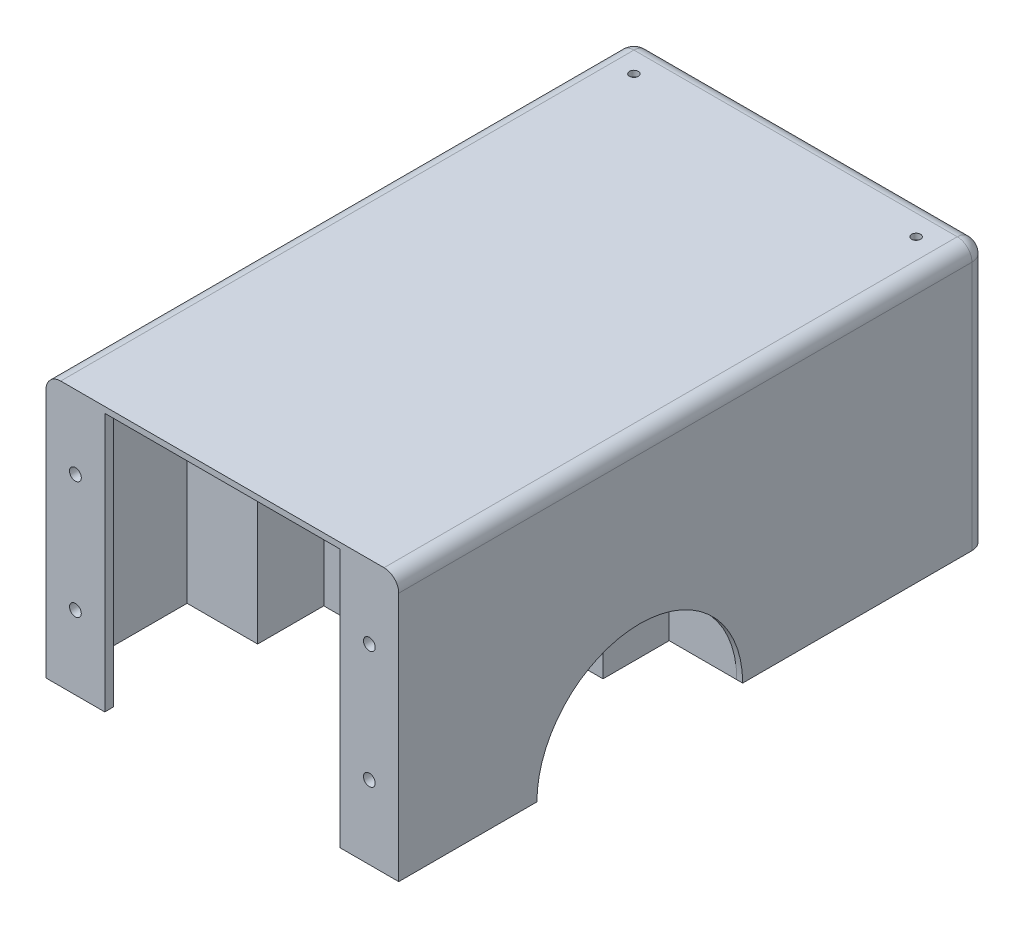
from build123d import *

# Parameters (mm, degrees)
BOSS_EXTRUDE1_DEPTH = 60
FILLET1_R           = 5
SHELL1_T            = -2
SKETCH2_R           = 2.675
BOSS_EXTRUDE2_DEPTH = 27
SKETCH3_R           = 1.425
CUT_EXTRUDE1_DEPTH  = 4
SKETCH4_W           = 18
SKETCH4_H           = 3
BOSS_EXTRUDE3_DEPTH = 88
SKETCH5_R           = 2
CUT_EXTRUDE2_DEPTH  = 3
BOSS_EXTRUDE4_DEPTH = 88
SKETCH8_R           = 1.5
CUT_EXTRUDE3_DEPTH  = 2
SKETCH9_R           = 2.5
BOSS_EXTRUDE5_DEPTH = 1
SKETCH10_R          = 4
SKETCH10_R_2        = 1.5
SKETCH10_R_3        = 2
CUT_EXTRUDE4_DEPTH  = 1
SKETCH11_R          = 2.425
SKETCH11_R_2        = 1.425
BOSS_EXTRUDE6_DEPTH = 3


with BuildPart() as part:
    # Sketch1 → Boss-Extrude1 (new body)
    with BuildSketch(Plane(origin=(0, 0, 0), x_dir=(0, 0, -1), z_dir=(1, 0, 0))):
        with BuildLine():
            Line((35, 0), (118, 0))
            Line((118, 0), (118, 90))
            Line((118, 90), (-82, 90))
            Line((-82, 90), (-82, 0))
            Line((-82, 0), (-35, 0))
            ThreePointArc((-35, 0), (0, 35), (35, 0))
        make_face()
    extrude(amount=BOSS_EXTRUDE1_DEPTH)

    # Fillet1
    fillet1_edges = [part.edges().sort_by_distance(p)[0] for p in [
        (60, 45, -118),
        (30, 90, -118),
        (60, 90, -18),
    ]]
    fillet(fillet1_edges, radius=FILLET1_R)

    # Shell1
    shell1_openings = [part.faces().sort_by_distance(p)[0] for p in [
        (30, 0, 58.5),
        (29.971275261, 44.956357534, 82),
        (29.96885008, 0, -76.456447556),
        (30, 17.5, 0),
        (0, 48.594891541, -20.122257458),
    ]]
    offset(amount=SHELL1_T, openings=shell1_openings, kind=Kind.INTERSECTION)

    # Sketch2 → Boss-Extrude2 (add)
    with BuildSketch(Plane.XZ.offset(-88)):
        with Locations(Location((41, -76, 0), (0, 0, 270))):  # turned: the seam where the file's is
            Circle(SKETCH2_R)
    extrude(amount=BOSS_EXTRUDE2_DEPTH)

    # Sketch3 → Cut-Extrude1 (cut)
    with BuildSketch(Plane.XZ.offset(-61)):
        with Locations(Location((41, -76, 0), (0, 0, 270))):  # turned: the seam where the file's is
            Circle(SKETCH3_R)
    extrude(amount=-CUT_EXTRUDE1_DEPTH, mode=Mode.SUBTRACT)

    # Sketch4 → Boss-Extrude3 (add)
    with BuildSketch(Plane.XZ):
        with Locations((49, 80.5)):
            Rectangle(SKETCH4_W, SKETCH4_H)
    extrude(amount=-BOSS_EXTRUDE3_DEPTH)

    # Sketch5 → Cut-Extrude2 (cut)
    with BuildSketch(Plane.XY.offset(82)):
        with Locations((50, 25)):
            Circle(SKETCH5_R)
        with Locations((50, 65)):
            Circle(SKETCH5_R)
    extrude(amount=-CUT_EXTRUDE2_DEPTH, mode=Mode.SUBTRACT)

    # Sketch6 → Boss-Extrude4 (add)
    with BuildSketch(Plane.XZ):
        Polygon((58, 35), (35, 35), (35, 12.5), (15, 12.5), (15, -12.5), (35, -12.5), (35, -35), (58, -35), (58, -36), (34, -36), (34, -13.5), (14, -13.5), (14, 13.5), (34, 13.5), (34, 36), (58, 36), align=None)
    extrude(amount=-BOSS_EXTRUDE4_DEPTH)

    # Sketch8 → Cut-Extrude3 (cut)
    with BuildSketch(Plane(origin=(0, 90, 0), x_dir=(1, 0, 0), z_dir=(0, 1, 0))):
        with Locations(Location((48, 106, 0), (0, 0, 270))):  # turned: the seam where the file's is
            Circle(SKETCH8_R)
    extrude(amount=-CUT_EXTRUDE3_DEPTH, mode=Mode.SUBTRACT)

    # Sketch9 → Boss-Extrude5 (add)
    with BuildSketch(Plane.XZ.offset(-88)):
        with Locations(Location((48, -106, 0), (0, 0, 270))):  # turned: the seam where the file's is
            Circle(SKETCH9_R)
        with BuildLine():
            Line((46.585786438, -105.5), (49.414213562, -105.5))
            ThreePointArc((49.414213562, -105.5), (49.5, -106), (49.414213562, -106.5))
            Line((49.414213562, -106.5), (46.585786438, -106.5))
            ThreePointArc((46.585786438, -106.5), (46.5, -106), (46.585786438, -105.5))
        make_face(mode=Mode.SUBTRACT)
    extrude(amount=BOSS_EXTRUDE5_DEPTH)

    # Sketch10 → Cut-Extrude4 (cut)
    with BuildSketch(Plane.ZY.offset(-14)):
        Circle(SKETCH10_R)
        with Locations((-8.75, 20.5)):
            Circle(SKETCH10_R_2)
        with Locations((8.75, 20.5)):
            Circle(SKETCH10_R_2)
        with Locations((-8.75, 47)):
            Circle(SKETCH10_R_3)
        with Locations((8.75, 47)):
            Circle(SKETCH10_R_3)
    extrude(amount=-CUT_EXTRUDE4_DEPTH, mode=Mode.SUBTRACT)

    # Mirror1: part across plane


with BuildPart() as part_1:
    add(part.part)
    add(part.part.mirror(Plane(origin=(0, 0, 0), x_dir=(0, 0, 1), z_dir=(1, 0, 0))))

    # Sketch11 → Boss-Extrude6 (add)
    with BuildSketch(Plane.XZ.offset(-88)):
        with Locations(Location((18.69, 23.5, 0), (0, 0, 270))):  # turned: the seam where the file's is
            Circle(SKETCH11_R)
        with Locations(Location((18.69, 23.5, 0), (0, 0, 270))):  # turned: the seam where the file's is
            Circle(SKETCH11_R_2, mode=Mode.SUBTRACT)
        with Locations(Location((18.69, 60.24, 0), (0, 0, 270))):  # turned: the seam where the file's is
            Circle(SKETCH11_R)
        with Locations(Location((18.69, 60.24, 0), (0, 0, 270))):  # turned: the seam where the file's is
            Circle(SKETCH11_R_2, mode=Mode.SUBTRACT)
        with Locations(Location((-18.69, 60.24, 0), (0, 0, 270))):  # turned: the seam where the file's is
            Circle(SKETCH11_R)
        with Locations(Location((-18.69, 60.24, 0), (0, 0, 270))):  # turned: the seam where the file's is
            Circle(SKETCH11_R_2, mode=Mode.SUBTRACT)
        with Locations(Location((-18.69, 23.5, 0), (0, 0, 270))):  # turned: the seam where the file's is
            Circle(SKETCH11_R)
        with Locations(Location((-18.69, 23.5, 0), (0, 0, 270))):  # turned: the seam where the file's is
            Circle(SKETCH11_R_2, mode=Mode.SUBTRACT)
    extrude(amount=BOSS_EXTRUDE6_DEPTH)


solid = part_1.part
